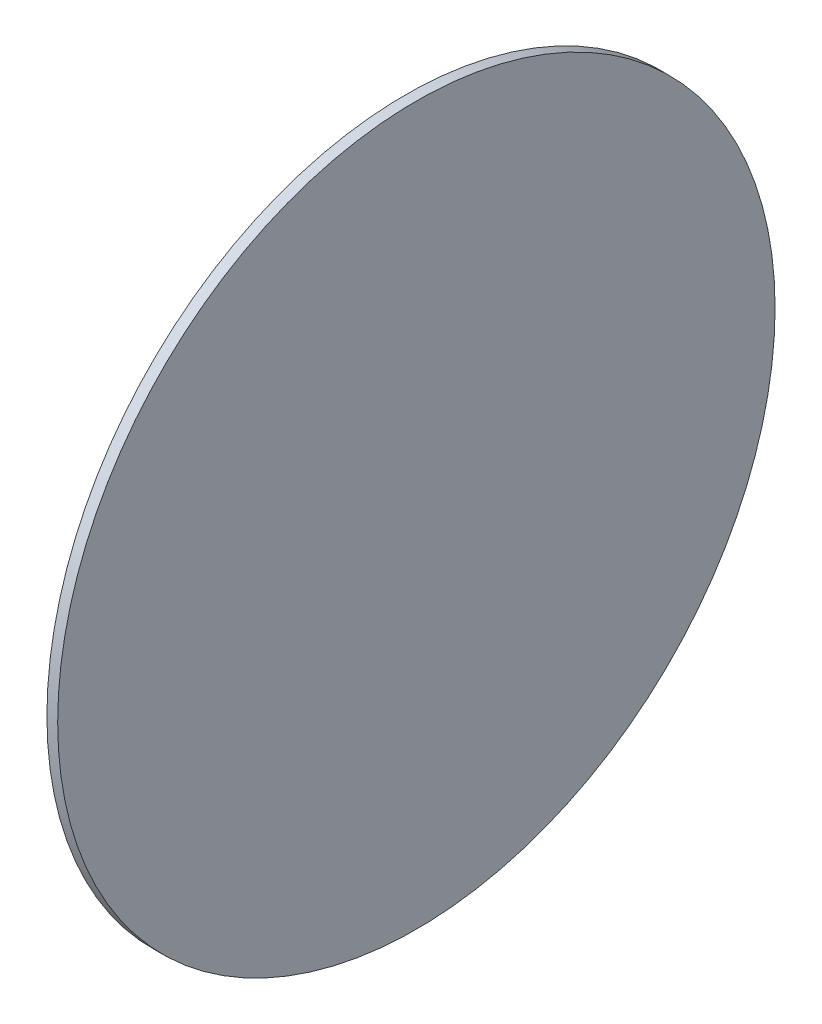
from build123d import *

# Parameters (mm, degrees)
SKETCH1_R           = 100
BOSS_EXTRUDE1_DEPTH = 3


with BuildPart() as part:
    # Sketch1 → Boss-Extrude1 (new body)
    with BuildSketch(Plane(origin=(0, 0, 0), x_dir=(0, 0, -1), z_dir=(1, 0, 0))):
        Circle(SKETCH1_R)
    extrude(amount=BOSS_EXTRUDE1_DEPTH)


solid = part.part
